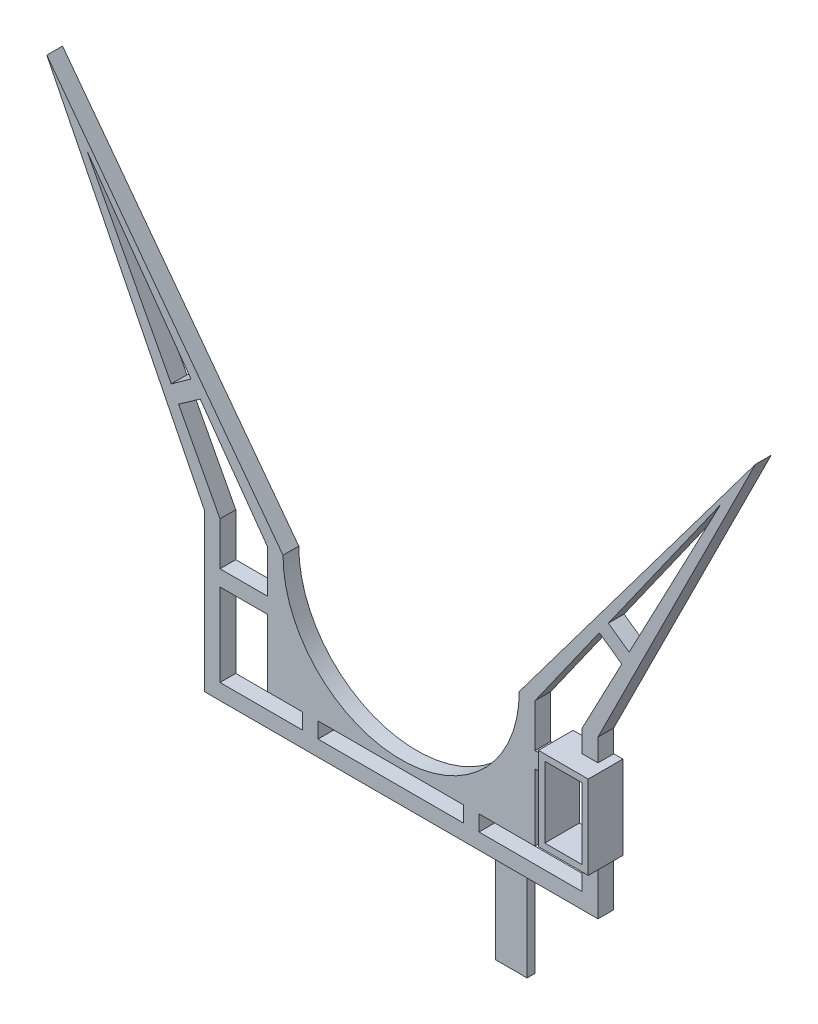
from build123d import *

# Parameters (mm, degrees)
BOSS_EXTRUDE1_DEPTH = 5
CUT_EXTRUDE1_DEPTH  = 10
SKETCH3_W           = 5
SKETCH3_H           = 5
SKETCH3_W_2         = 15
BOSS_EXTRUDE2_DEPTH = 5
SKETCH5_W           = 10
SKETCH5_H           = 30
BOSS_EXTRUDE3_DEPTH = 2.5
SKETCH6_W           = 5.9
SKETCH6_H           = 4.637740471
SKETCH6_H_2         = 12.862259529
SKETCH6_W_2         = 5
SKETCH6_H_3         = 2
SKETCH6_W_3         = 2
SKETCH6_H_4         = 3.737740471
SKETCH6_H_5         = 1.262259529
BOSS_EXTRUDE6_DEPTH = 5
SKETCH7_W           = 0.9
SKETCH7_H           = 22.5
BOSS_EXTRUDE7_DEPTH = 5
SKETCH8_W           = 11.8
SKETCH8_H           = 22.5
CUT_EXTRUDE2_DEPTH  = 5
SKETCH9_W           = 15.8
SKETCH9_H           = 26.5
SKETCH9_W_2         = 11.8
SKETCH9_H_2         = 22.5
BOSS_EXTRUDE8_DEPTH = 6


with BuildPart() as part:
    # Sketch1 → Boss-Extrude1 (new body)
    with BuildSketch(Plane.XY):
        Polygon((-37.5, 25), (-112.5, 125), (-62.5, 25), align=None)
        with BuildLine():
            Line((-37.5, 25), (-62.5, 25))
            Line((-62.5, 25), (-62.5, -25))
            Line((-62.5, -25), (62.5, -25))
            Line((62.5, -25), (62.5, 25))
            Line((62.5, 25), (37.5, 25))
            ThreePointArc((37.5, 25), (0, -12.5), (-37.5, 25))
        make_face()
        Polygon((112.5, 125), (37.5, 25), (62.5, 25), align=None)
    extrude(amount=BOSS_EXTRUDE1_DEPTH)

    # Sketch2 → Cut-Extrude1 (cut)
    with BuildSketch(Plane.XY.offset(5)):
        Polygon((42.5, -15), (-42.5, -15), (-42.5, 25), (-57.5, 25), (-57.5, -20), (57.5, -20), (57.5, 25), (42.5, 25), align=None)
        Polygon((-57.5, 25), (-42.5, 25), (-99.706643081, 105), align=None)
        Polygon((101.413859584, 108.353754457), (42.5, 25), (57.5, 25), align=None)
    extrude(amount=-CUT_EXTRUDE1_DEPTH, mode=Mode.SUBTRACT)

    # Sketch3 → Boss-Extrude2 (add)
    with BuildSketch(Plane.XY.offset(5)):
        with Locations((-28.877625422, -17.5)):
            Rectangle(SKETCH3_W, SKETCH3_H)
        with Locations((22.225490127, -17.5)):
            Rectangle(SKETCH3_W, SKETCH3_H)
        with Locations((50, 8.762259529)):
            Rectangle(SKETCH3_W_2, SKETCH3_H)
        with Locations((-50, 8.762259529)):
            Rectangle(SKETCH3_W_2, SKETCH3_H)
        Polygon((-70.654305037, 49.93314621), (-63.796030498, 54.781199316), (-66.704368337, 58.848332338), (-72.987424539, 54.355425418), align=None)
        Polygon((65.786619226, 57.946867762), (62.925217298, 53.89843849), (70.065851227, 48.851487608), (72.396389437, 53.275127699), align=None)
    extrude(amount=-BOSS_EXTRUDE2_DEPTH)

    # Sketch5 → Boss-Extrude3 (add)
    with BuildSketch(Plane(origin=(0, 0, 0), x_dir=(-1, 0, 0), z_dir=(0, 0, -1))):
        with Locations((-32.5, -40)):
            Rectangle(SKETCH5_W, SKETCH5_H)
    extrude(amount=-BOSS_EXTRUDE3_DEPTH)

    # Sketch6 → Boss-Extrude6 (add)
    with BuildSketch(Plane.XY.offset(5)):
        with Locations((54.55, 13.581129765)):
            Rectangle(SKETCH6_W, SKETCH6_H)
        Polygon((51.6, 11.262259529), (51.6, 10), (57.5, 10), (62.5, 10), (62.5, 15.9), (57.5, 15.9), (57.5, 11.262259529), align=None)
        Polygon((57.5, 10), (51.6, 10), (51.6, 6.262259529), (57.5, 6.262259529), (57.5, -6.6), (62.5, -6.6), (62.5, 10), align=None)
        with Locations((54.55, -0.168870236)):
            Rectangle(SKETCH6_W, SKETCH6_H_2)
        Polygon((63.4, 15.9), (63.4, 10), (63.4, -6.6), (62.5, -6.6), (62.5, -8.6), (65.4, -8.6), (65.4, 17.9), (62.5, 17.9), (62.5, 15.9), align=None)
        with Locations((60, 16.9)):
            Rectangle(SKETCH6_W_2, SKETCH6_H_3)
        Polygon((49.6, 11.262259529), (51.6, 11.262259529), (51.6, 15.9), (57.5, 15.9), (57.5, 17.9), (49.6, 17.9), align=None)
        Polygon((51.6, -6.6), (51.6, 6.262259529), (49.6, 6.262259529), (49.6, -8.6), (57.5, -8.6), (57.5, -6.6), align=None)
        with Locations((60, -7.6)):
            Rectangle(SKETCH6_W_2, SKETCH6_H_3)
        with Locations((50.6, 8.131129765)):
            Rectangle(SKETCH6_W_3, SKETCH6_H_4)
        with Locations((50.6, 10.631129765)):
            Rectangle(SKETCH6_W_3, SKETCH6_H_5)
    extrude(amount=-BOSS_EXTRUDE6_DEPTH)

    # Sketch7 → Boss-Extrude7 (add)
    with BuildSketch(Plane.XY.offset(5)):
        with Locations((62.95, 4.65)):
            Rectangle(SKETCH7_W, SKETCH7_H)
    extrude(amount=-BOSS_EXTRUDE7_DEPTH)

    # Sketch8 → Cut-Extrude2 (cut)
    with BuildSketch(Plane.XY.offset(5)):
        with Locations((57.5, 4.65)):
            Rectangle(SKETCH8_W, SKETCH8_H)
    extrude(amount=-CUT_EXTRUDE2_DEPTH, mode=Mode.SUBTRACT)

    # Sketch9 → Boss-Extrude8 (add)
    with BuildSketch(Plane.XY.offset(5)):
        with Locations((57.5, 4.65)):
            Rectangle(SKETCH9_W, SKETCH9_H)
        with Locations((57.5, 4.65)):
            Rectangle(SKETCH9_W_2, SKETCH9_H_2, mode=Mode.SUBTRACT)
    extrude(amount=BOSS_EXTRUDE8_DEPTH)


solid = part.part
